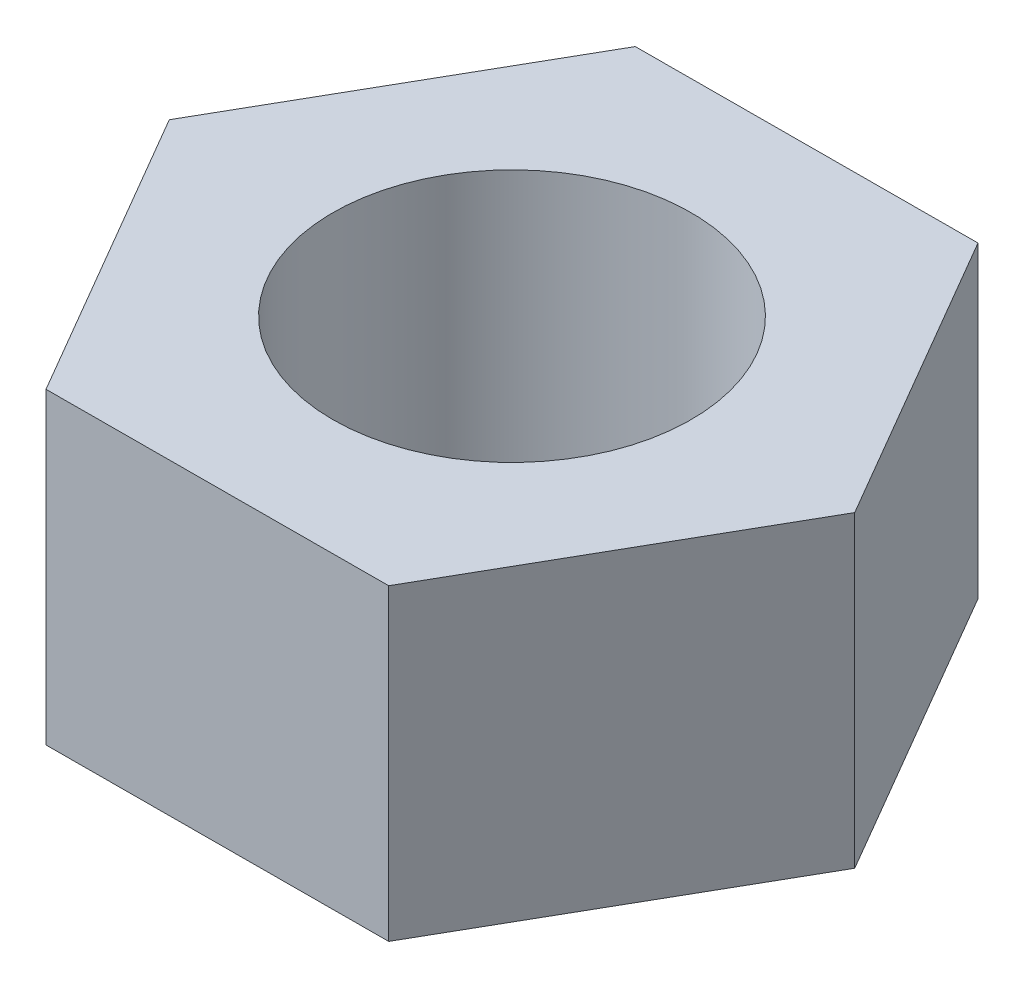
from build123d import *

# Parameters (mm, degrees)
BOSS_EXTRUDE1_DEPTH = 13.97
SKETCH2_R           = 8.128
CUT_EXTRUDE1_DEPTH  = 14.97


with BuildPart() as part:
    # Sketch1 → Boss-Extrude1 (new body)
    with BuildSketch(Plane(origin=(0, 0, 0), x_dir=(1, 0, 0), z_dir=(0, 1, 0))):
        Polygon((7.693812666, 13.439455367), (-7.792003428, 13.382764905), (-15.485816094, -0.056690463), (-7.693812666, -13.439455367), (7.792003428, -13.382764905), (15.485816094, 0.056690463), align=None)
    extrude(amount=BOSS_EXTRUDE1_DEPTH)

    # Sketch2 → Cut-Extrude1 (cut, through all)
    with BuildSketch(Plane(origin=(0, 13.97, 0), x_dir=(1, 0, 0), z_dir=(0, 1, 0))):
        Circle(SKETCH2_R)
    extrude(amount=-CUT_EXTRUDE1_DEPTH, mode=Mode.SUBTRACT)


solid = part.part
